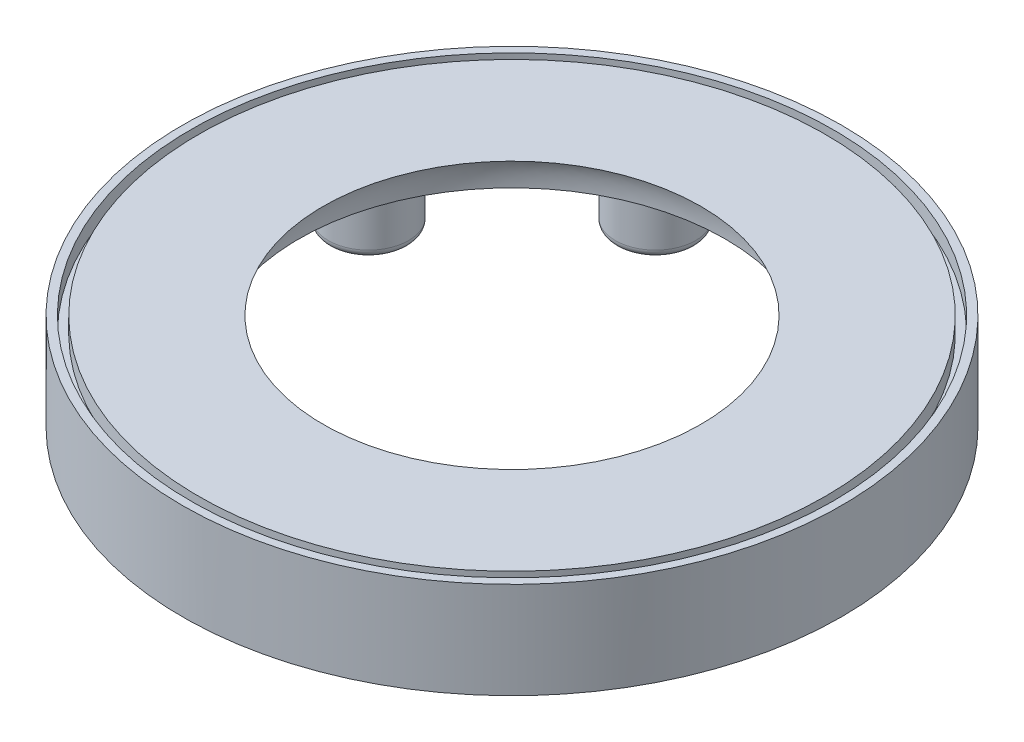
from build123d import *

# Parameters (mm, degrees)
BOSS_EXTRUDE1_DEPTH     = 2
FILLET1_R               = 0.5
SKETCH5_R               = 41
SKETCH5_R_2             = 40
EXTRUDE_THIN1_DEPTH     = 7
SKETCH13_R              = 40
SKETCH13_R_2            = 39
CUT_EXTRUDE_THIN2_DEPTH = 2
SKETCH14_R              = 5
BOSS_EXTRUDE2_DEPTH     = 7
SKETCH15_R              = 3
CUT_EXTRUDE1_DEPTH      = 3
FILLET2_R               = 1


with BuildPart() as part:
    # Sketch3 → Revolve1 (revolve)
    with BuildSketch(Plane.XY):
        with BuildLine():
            Line((-26.5, 0), (-41, 0))
            Line((-41, 0), (-41, 5))
            Line((-41, 5), (-23.5, 5))
            add(Edge.make_bspline(
                [(-26.5, 0), (-26.5, 5), (-23.5, 5)],
                knots=[0, 0, 0, 1, 1, 1], degree=2))
        make_face()
    revolve(axis=Axis((0, 0, 0), (0, 1, 0)))

    # Sketch4 → Boss-Extrude1 (add)
    with BuildSketch(Plane.XZ):
        with BuildLine():
            Line((-33, 1.9), (-33, -1.9))
            ThreePointArc((-33, -1.9), (-31.1, 0), (-33, 1.9))
        make_face()
        with BuildLine():
            Line((-35, 1.9), (-35, -1.9))
            ThreePointArc((-35, -1.9), (-36.9, 0), (-35, 1.9))
        make_face()
        with BuildLine():
            Line((1.9, 33), (-1.9, 33))
            ThreePointArc((-1.9, 33), (0, 31.1), (1.9, 33))
        make_face()
        with BuildLine():
            Line((1.9, 35), (-1.9, 35))
            ThreePointArc((-1.9, 35), (0, 36.9), (1.9, 35))
        make_face()
        with BuildLine():
            Line((33, -1.9), (33, 1.9))
            ThreePointArc((33, 1.9), (31.1, 0), (33, -1.9))
        make_face()
        with BuildLine():
            Line((35, -1.9), (35, 1.9))
            ThreePointArc((35, 1.9), (36.9, 0), (35, -1.9))
        make_face()
        with BuildLine():
            Line((-1.9, -33), (1.9, -33))
            ThreePointArc((1.9, -33), (0, -31.1), (-1.9, -33))
        make_face()
        with BuildLine():
            Line((-1.9, -35), (1.9, -35))
            ThreePointArc((1.9, -35), (0, -36.9), (-1.9, -35))
        make_face()
    extrude(amount=BOSS_EXTRUDE1_DEPTH)

    # Fillet1
    fillet1_edges = [part.edges().sort_by_distance(p)[0] for p in [
        (-35, 0, 0),
        (-36.9, -2, 0),
        (-35, -2, 0),
        (-33, 0, 0),
        (-31.1, -2, 0),
        (-33, -2, 0),
        (0, 0, 35),
        (0, -2, 36.9),
        (0, -2, 35),
        (0, 0, 33),
        (0, -2, 31.1),
        (0, -2, 33),
        (35, 0, 0),
        (36.9, -2, 0),
        (35, -2, 0),
        (33, 0, 0),
        (31.1, -2, 0),
        (33, -2, 0),
        (0, 0, -35),
        (0, -2, -36.9),
        (0, -2, -35),
        (0, 0, -33),
        (0, -2, -31.1),
        (0, -2, -33),
    ]]
    fillet(fillet1_edges, radius=FILLET1_R)

    # Sketch5 → Extrude-Thin1 (add)
    with BuildSketch(Plane.XZ):
        Circle(SKETCH5_R)
        Circle(SKETCH5_R_2, mode=Mode.SUBTRACT)
    extrude(amount=EXTRUDE_THIN1_DEPTH)

    # Sketch13 → Cut-Extrude-Thin2 (cut)
    with BuildSketch(Plane(origin=(0, 5, 0), x_dir=(1, 0, 0), z_dir=(0, 1, 0))):
        Circle(SKETCH13_R)
        Circle(SKETCH13_R_2, mode=Mode.SUBTRACT)
    extrude(amount=-CUT_EXTRUDE_THIN2_DEPTH, mode=Mode.SUBTRACT)

    # Sketch14 → Boss-Extrude2 (add)
    with BuildSketch(Plane.XZ):
        with Locations((12.628553268, -30.488024573)):
            Circle(SKETCH14_R)
        with Locations((-12.628553268, -30.488024573)):
            Circle(SKETCH14_R)
        with Locations((-30.488024573, -12.628553268)):
            Circle(SKETCH14_R)
        with Locations((-30.488024573, 12.628553268)):
            Circle(SKETCH14_R)
        with Locations((-12.628553268, 30.488024573)):
            Circle(SKETCH14_R)
        with Locations((12.628553268, 30.488024573)):
            Circle(SKETCH14_R)
        with Locations((30.488024573, 12.628553268)):
            Circle(SKETCH14_R)
        with Locations((30.488024573, -12.628553268)):
            Circle(SKETCH14_R)
    extrude(amount=BOSS_EXTRUDE2_DEPTH)

    # Sketch15 → Cut-Extrude1 (cut)
    with BuildSketch(Plane.XZ.offset(7)):
        with Locations((-12.628553268, -30.488024573)):
            Circle(SKETCH15_R)
        with Locations((-30.488024573, -12.628553268)):
            Circle(SKETCH15_R)
        with Locations((-30.488024573, 12.628553268)):
            Circle(SKETCH15_R)
        with Locations((-12.628553268, 30.488024573)):
            Circle(SKETCH15_R)
        with Locations((12.628553268, 30.488024573)):
            Circle(SKETCH15_R)
        with Locations((30.488024573, 12.628553268)):
            Circle(SKETCH15_R)
        with Locations((30.488024573, -12.628553268)):
            Circle(SKETCH15_R)
        with Locations((12.628553268, -30.488024573)):
            Circle(SKETCH15_R)
    extrude(amount=-CUT_EXTRUDE1_DEPTH, mode=Mode.SUBTRACT)

    # Fillet2
    fillet2_edges = [part.edges().sort_by_distance(p)[0] for p in [
        (7.628553268, 0, -30.488024573),
        (7.628553268, -7, -30.488024573),
        (-17.628553268, 0, -30.488024573),
        (-17.628553268, -7, -30.488024573),
        (-35.488024573, 0, -12.628553268),
        (-35.488024573, -7, -12.628553268),
        (-35.488024573, 0, 12.628553268),
        (-35.488024573, -7, 12.628553268),
        (-17.628553268, 0, 30.488024573),
        (-17.628553268, -7, 30.488024573),
        (7.628553268, 0, 30.488024573),
        (7.628553268, -7, 30.488024573),
        (25.488024573, 0, 12.628553268),
        (25.488024573, -7, 12.628553268),
        (25.488024573, 0, -12.628553268),
        (25.488024573, -7, -12.628553268),
    ]]
    fillet(fillet2_edges, radius=FILLET2_R)


solid = part.part
